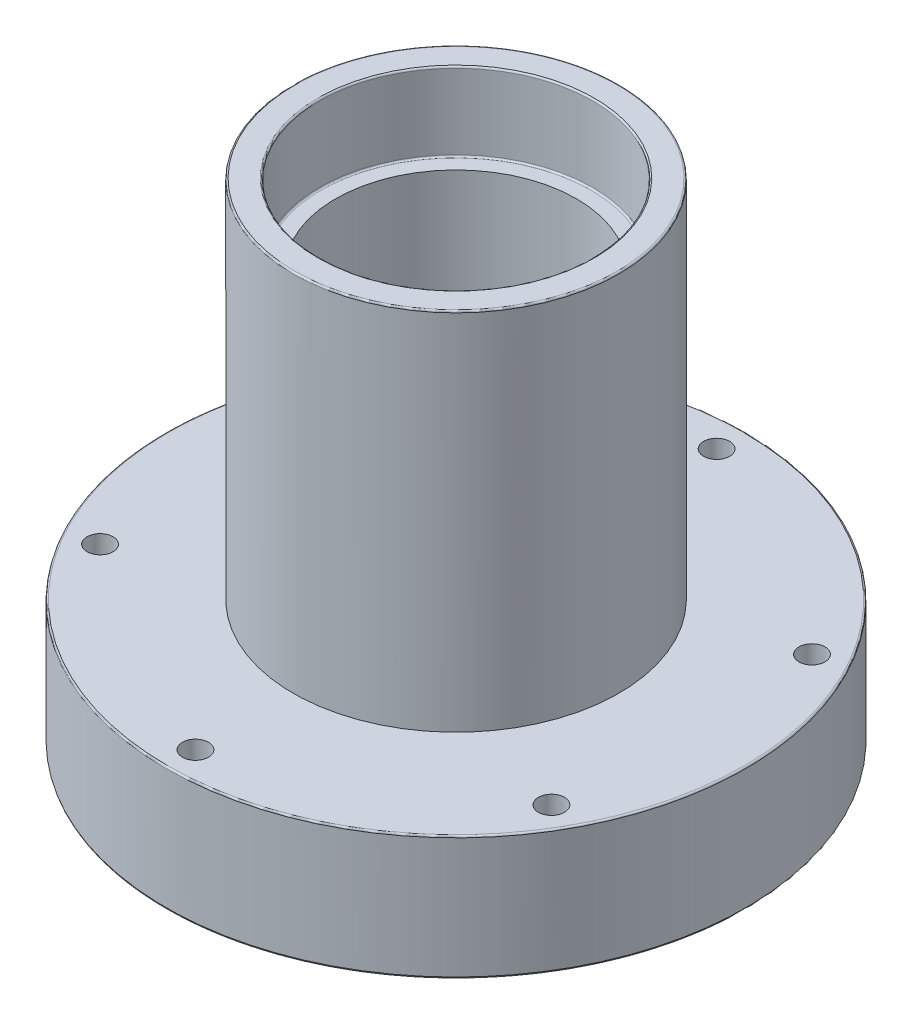
from build123d import *

# Parameters (mm, degrees)
SKETCH2_R          = 2
CUT_EXTRUDE1_DEPTH = 20
FILLET1_R          = 0.25


with BuildPart() as part:
    # Sketch1 → Revolve1 (revolve)
    with BuildSketch(Plane(origin=(0, 0, 0), x_dir=(0, 0, -1), z_dir=(1, 0, 0))):
        Polygon((21, 0), (21, 12), (18.5, 12), (18.5, 63), (21, 63), (21, 75), (25, 75), (25, 19), (44.5, 19), (44.5, 0), align=None)
    revolve(axis=Axis((0, -1000.237288136, 0), (0, 1, 0)))

    # Sketch2 → Cut-Extrude1 (cut, through all)
    with BuildSketch(Plane(origin=(0, 19, 0), x_dir=(1, 0, 0), z_dir=(0, 1, 0))):
        with Locations((0, 40)):
            Circle(SKETCH2_R)
        with Locations((34.641016151, 20)):
            Circle(SKETCH2_R)
        with Locations((34.641016151, -20)):
            Circle(SKETCH2_R)
        with Locations((0, -40)):
            Circle(SKETCH2_R)
        with Locations((-34.641016151, -20)):
            Circle(SKETCH2_R)
        with Locations((-34.641016151, 20)):
            Circle(SKETCH2_R)
    extrude(amount=-CUT_EXTRUDE1_DEPTH, mode=Mode.SUBTRACT)

    # Fillet1
    fillet1_edges = [part.edges().sort_by_distance(p)[0] for p in [
        (0, 12, 21),
        (0, 0, 44.5),
        (0, 19, 44.5),
        (0, 75, 25),
        (0, 75, 21),
        (0, 63, 21),
    ]]
    fillet(fillet1_edges, radius=FILLET1_R)


solid = part.part
